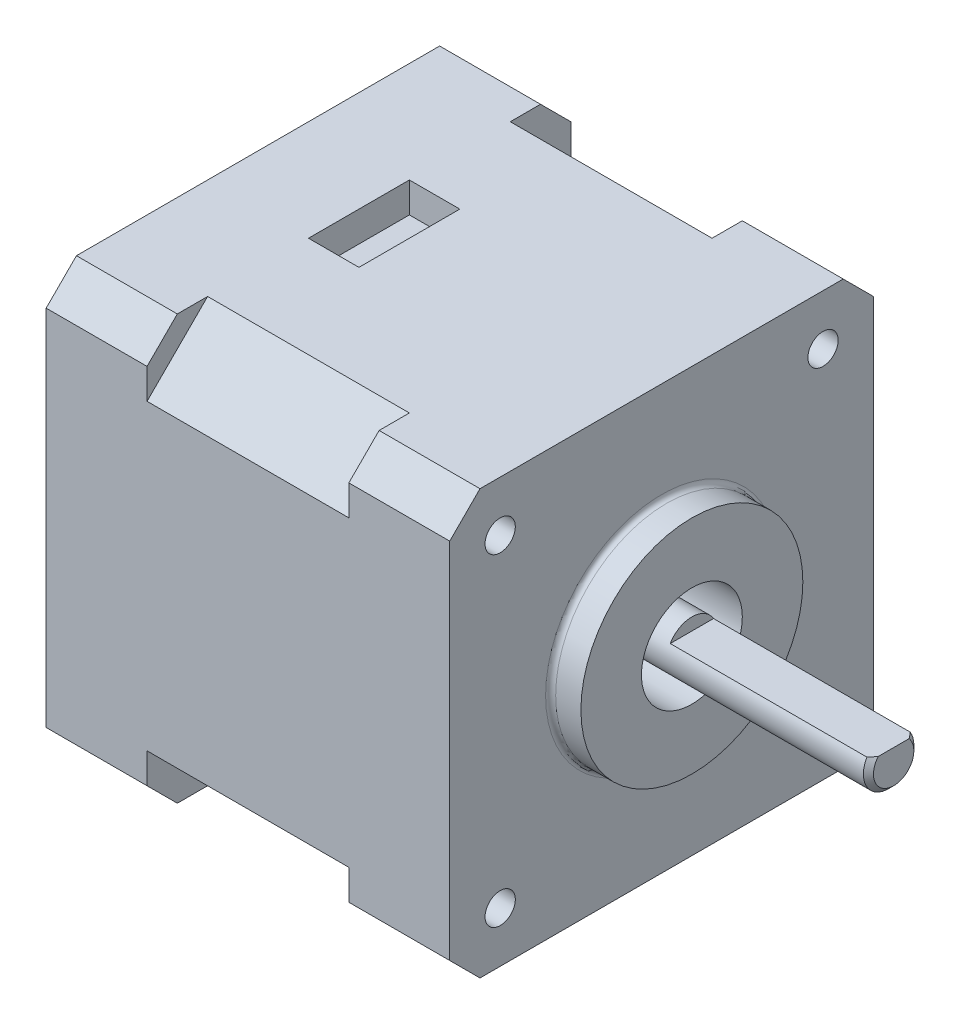
from build123d import *

# Parameters (mm, degrees)
BOSS_EXTRU_1_DEPTH      = 10
ESQUISSE2_W             = 42
ESQUISSE2_H             = 42
BOSS_EXTRU_2_DEPTH      = 10
ESQUISSE3_W             = 42
ESQUISSE3_H             = 42
BOSS_EXTRU_3_DEPTH      = 10
ESQUISSE4_R             = 11
BOSS_EXTRU_4_DEPTH      = 3
CONG_1_R                = 0.5
ESQUISSE5_R             = 5
ENL_V_MAT_EXTRU_1_DEPTH = 10
ESQUISSE6_R             = 2.5
BOSS_EXTRU_5_DEPTH      = 30
ENL_V_MAT_EXTRU_2_DEPTH = 20
CHANFREIN1_SIZE         = 0.5
ESQUISSE8_R             = 1.5
ENL_V_MAT_EXTRU_3_DEPTH = 5
ENL_V_MAT_EXTRU_5_DEPTH = 41
ESQUISSE11_W            = 5
ESQUISSE11_H            = 10
ENL_V_MAT_EXTRU_6_DEPTH = 3


with BuildPart() as part:
    # Esquisse1 → Boss.-Extru.1 (new body, symmetric)
    with BuildSketch(Plane(origin=(0, 0, 0), x_dir=(0, 0, -1), z_dir=(1, 0, 0))):
        Polygon((6, 0), (36, 0), (42, -6), (42, -36), (36, -42), (6, -42), (0, -36), (0, -6), align=None)
    extrude(amount=BOSS_EXTRU_1_DEPTH, both=True)

    # Esquisse2 → Boss.-Extru.2 (add)
    with BuildSketch(Plane(origin=(10, 0, 0), x_dir=(0, 0, -1), z_dir=(1, 0, 0))):
        with Locations((21, -21)):
            Rectangle(ESQUISSE2_W, ESQUISSE2_H)
    extrude(amount=BOSS_EXTRU_2_DEPTH)

    # Esquisse3 → Boss.-Extru.3 (add)
    with BuildSketch(Plane.ZY.offset(10)):
        with Locations((-21, -21)):
            Rectangle(ESQUISSE3_W, ESQUISSE3_H)
    extrude(amount=BOSS_EXTRU_3_DEPTH)

    # Esquisse4 → Boss.-Extru.4 (add)
    with BuildSketch(Plane(origin=(20, 0, 0), x_dir=(0, 0, -1), z_dir=(1, 0, 0))):
        with Locations((21, -21)):
            Circle(ESQUISSE4_R)
    extrude(amount=BOSS_EXTRU_4_DEPTH)

    # Congé1
    cong_1_edges = [part.edges().sort_by_distance(p)[0] for p in [
        (20, -21, -10),
    ]]
    fillet(cong_1_edges, radius=CONG_1_R)

    # Esquisse5 → Enlèv. mat.-Extru.1 (cut)
    with BuildSketch(Plane(origin=(23, 0, 0), x_dir=(0, 0, -1), z_dir=(1, 0, 0))):
        with Locations((21, -21)):
            Circle(ESQUISSE5_R)
    extrude(amount=-ENL_V_MAT_EXTRU_1_DEPTH, mode=Mode.SUBTRACT)

    # Esquisse6 → Boss.-Extru.5 (add)
    with BuildSketch(Plane(origin=(13, 0, 0), x_dir=(0, 0, -1), z_dir=(1, 0, 0))):
        with Locations((21, -21)):
            Circle(ESQUISSE6_R)
    extrude(amount=BOSS_EXTRU_5_DEPTH)

    # Esquisse7 → Enlèv. mat.-Extru.2 (cut)
    with BuildSketch(Plane(origin=(43, 0, 0), x_dir=(0, 0, -1), z_dir=(1, 0, 0))):
        with BuildLine():
            Line((18.853641827, -19.718147202), (23.146358173, -19.718147202))
            ThreePointArc((23.146358173, -19.718147202), (21, -18.5), (18.853641827, -19.718147202))
        make_face()
    extrude(amount=-ENL_V_MAT_EXTRU_2_DEPTH, mode=Mode.SUBTRACT)

    # Chanfrein1
    chanfrein1_edges = [part.edges().sort_by_distance(p)[0] for p in [
        (43, -23.409968406, -20.335129874),
    ]]
    chamfer(chanfrein1_edges, length=CHANFREIN1_SIZE)

    # Esquisse8 → Enlèv. mat.-Extru.3 (cut)
    with BuildSketch(Plane(origin=(20, 0, 0), x_dir=(0, 0, -1), z_dir=(1, 0, 0))):
        with Locations((5, -5)):
            Circle(ESQUISSE8_R)
        with Locations((37, -5)):
            Circle(ESQUISSE8_R)
        with Locations((5, -37)):
            Circle(ESQUISSE8_R)
        with Locations((37, -37)):
            Circle(ESQUISSE8_R)
    extrude(amount=-ENL_V_MAT_EXTRU_3_DEPTH, mode=Mode.SUBTRACT)

    # Esquisse9 → Enlèv. mat.-Extru.5 (cut, through all)
    with BuildSketch(Plane(origin=(20, 0, 0), x_dir=(0, 0, -1), z_dir=(1, 0, 0))):
        Polygon((3, 0), (0, -3), (0, 0), align=None)
        Polygon((39, 0), (42, -3), (42, 0), align=None)
        Polygon((3, -42), (0, -39), (0, -42), align=None)
        Polygon((39, -42), (42, -39), (42, -42), align=None)
    extrude(amount=-ENL_V_MAT_EXTRU_5_DEPTH, mode=Mode.SUBTRACT)

    # Esquisse11 → Enlèv. mat.-Extru.6 (cut)
    with BuildSketch(Plane(origin=(0, 0, 0), x_dir=(1, 0, 0), z_dir=(0, 1, 0))):
        with Locations((-7.5, 21)):
            Rectangle(ESQUISSE11_W, ESQUISSE11_H)
    extrude(amount=-ENL_V_MAT_EXTRU_6_DEPTH, mode=Mode.SUBTRACT)


solid = part.part
